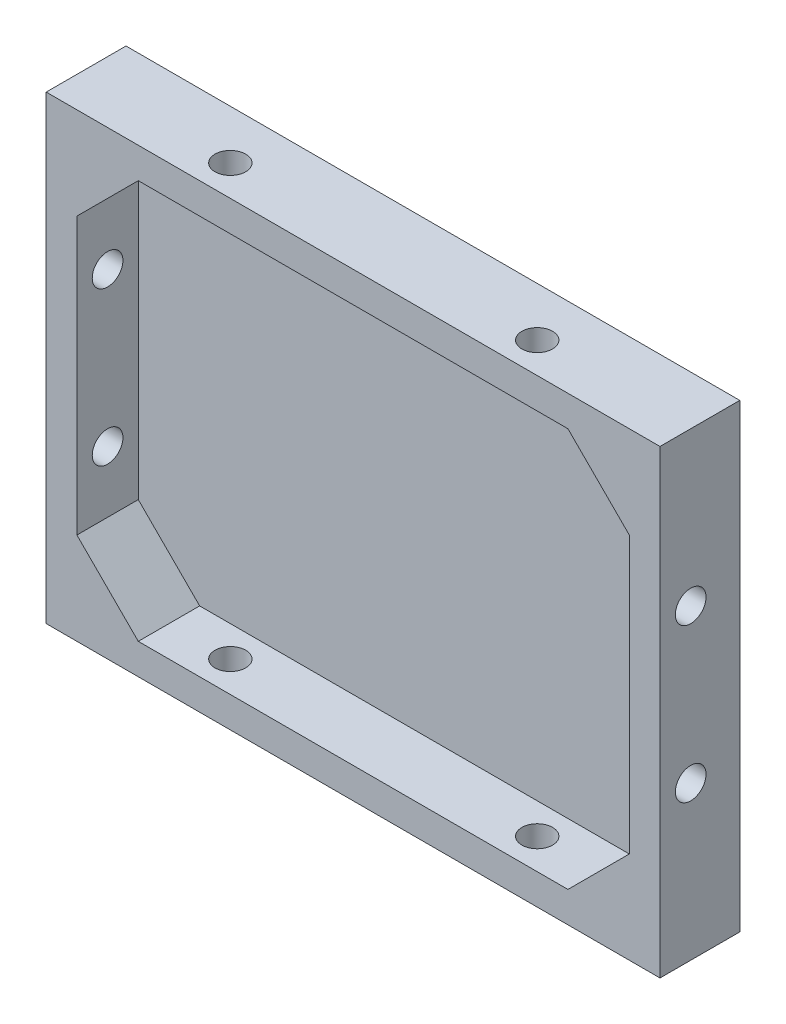
from build123d import *

# Parameters (mm, degrees)
BOSS_EXTRU_1_DEPTH        = 13
COQUE1_T                  = -5
COQUE1_THICKNESS_2_FACE_W = 90
COQUE1_THICKNESS_2_FACE_H = 65
COQUE1_THICKNESS_2_DEPTH  = 2
ENL_V_MAT_EXTRU_1_REACH   = 110.96
ESQUISSE2_R               = 2.5
ENL_V_MAT_EXTRU_2_REACH   = 95.396
ESQUISSE3_R               = 2.5
BOSS_EXTRU_2_DEPTH        = 10


with BuildPart() as part:
    # Esquisse1 → Boss.-Extru.1 (new body)
    with BuildSketch(Plane.XY):
        Polygon((44.118436308, 33.728448276), (54.118436308, 33.728448276), (54.118436308, 23.728448276), (54.118436308, -41.271551724), (-45.881563692, -41.271551724), (-45.881563692, 33.728448276), align=None)
    extrude(amount=BOSS_EXTRU_1_DEPTH)

    # Coque1
    coque1_openings = [part.faces().sort_by_distance(p)[0] for p in [
        (4.118436308, -3.771551724, 13),
    ]]
    offset(amount=COQUE1_T, openings=coque1_openings, kind=Kind.INTERSECTION)

    # Coque1 thickness 2 face (on inner face of the shell) → Coque1 thickness 2 (cut)
    with BuildSketch(Plane(origin=(4.118436308, -3.771551724, 5), x_dir=(-1, 0, 0), z_dir=(0, 0, -1))):
        Rectangle(COQUE1_THICKNESS_2_FACE_W, COQUE1_THICKNESS_2_FACE_H)
    extrude(amount=COQUE1_THICKNESS_2_DEPTH, mode=Mode.SUBTRACT)

    # Enlèv. mat.-Extru.1: up to this face of the body (flat: up to its plane)
    enl_v_mat_extru_1_end = Plane(part.part.faces().sort_by_distance((54.118436308, -3.771551724, 6.5))[0])
    # Esquisse2 → Enlèv. mat.-Extru.1 (cut, up to the picked face)
    with BuildSketch(Plane.ZY.offset(45.881563692), mode=Mode.PRIVATE) as enl_v_mat_extru_1_sk1:
        with Locations(Location((8, -16.271551724, 0), (0, 0, 270))):
            Circle(ESQUISSE2_R)
    enl_v_mat_extru_1_tool1 = split(extrude(enl_v_mat_extru_1_sk1.sketch, amount=-ENL_V_MAT_EXTRU_1_REACH, mode=Mode.PRIVATE), bisect_by=enl_v_mat_extru_1_end, keep=Keep.BOTH, mode=Mode.PRIVATE)
    # Esquisse2 → Enlèv. mat.-Extru.1 (cut, up to the picked face)
    with BuildSketch(Plane.ZY.offset(45.881563692), mode=Mode.PRIVATE) as enl_v_mat_extru_1_sk2:
        with Locations(Location((8, 8.728448276, 0), (0, 0, 270))):
            Circle(ESQUISSE2_R)
    enl_v_mat_extru_1_tool2 = split(extrude(enl_v_mat_extru_1_sk2.sketch, amount=-ENL_V_MAT_EXTRU_1_REACH, mode=Mode.PRIVATE), bisect_by=enl_v_mat_extru_1_end, keep=Keep.BOTH, mode=Mode.PRIVATE)
    add(enl_v_mat_extru_1_tool1.solids().sort_by(Axis((-45.881564, -16.271552, 8), (1, 0, 0)))[0], mode=Mode.SUBTRACT)
    add(enl_v_mat_extru_1_tool2.solids().sort_by(Axis((-45.881564, 8.728448, 8), (1, 0, 0)))[0], mode=Mode.SUBTRACT)

    # Enlèv. mat.-Extru.2: up to this face of the body (flat: up to its plane)
    enl_v_mat_extru_2_end = Plane(part.part.faces().sort_by_distance((4.118436308, 33.728448276, 6.5))[0])
    # Esquisse3 → Enlèv. mat.-Extru.2 (cut, up to the picked face)
    with BuildSketch(Plane.XZ.offset(41.271551724), mode=Mode.PRIVATE) as enl_v_mat_extru_2_sk1:
        with Locations(Location((-20.881563692, 8, 0), (0, 0, 270))):
            Circle(ESQUISSE3_R)
    enl_v_mat_extru_2_tool1 = split(extrude(enl_v_mat_extru_2_sk1.sketch, amount=-ENL_V_MAT_EXTRU_2_REACH, mode=Mode.PRIVATE), bisect_by=enl_v_mat_extru_2_end, keep=Keep.BOTH, mode=Mode.PRIVATE)
    # Esquisse3 → Enlèv. mat.-Extru.2 (cut, up to the picked face)
    with BuildSketch(Plane.XZ.offset(41.271551724), mode=Mode.PRIVATE) as enl_v_mat_extru_2_sk2:
        with Locations(Location((29.118436308, 8, 0), (0, 0, 270))):
            Circle(ESQUISSE3_R)
    enl_v_mat_extru_2_tool2 = split(extrude(enl_v_mat_extru_2_sk2.sketch, amount=-ENL_V_MAT_EXTRU_2_REACH, mode=Mode.PRIVATE), bisect_by=enl_v_mat_extru_2_end, keep=Keep.BOTH, mode=Mode.PRIVATE)
    add(enl_v_mat_extru_2_tool1.solids().sort_by(Axis((-20.881564, -41.271552, 8), (0, 1, 0)))[0], mode=Mode.SUBTRACT)
    add(enl_v_mat_extru_2_tool2.solids().sort_by(Axis((29.118436, -41.271552, 8), (0, 1, 0)))[0], mode=Mode.SUBTRACT)

    # Esquisse4 → Boss.-Extru.2 (add)
    with BuildSketch(Plane.XY.offset(3)):
        Polygon((-30.881563692, 28.728448276), (-40.881563692, 18.728448276), (-40.881563692, 28.728448276), align=None)
        Polygon((49.118436308, 28.728448276), (49.118436308, 18.728448276), (39.118436308, 28.728448276), align=None)
        Polygon((49.118436308, -36.271551724), (49.118436308, -26.271551724), (39.118436308, -36.271551724), align=None)
        Polygon((-30.881563692, -36.271551724), (-40.881563692, -26.271551724), (-40.881563692, -36.271551724), align=None)
    extrude(amount=BOSS_EXTRU_2_DEPTH)


solid = part.part
